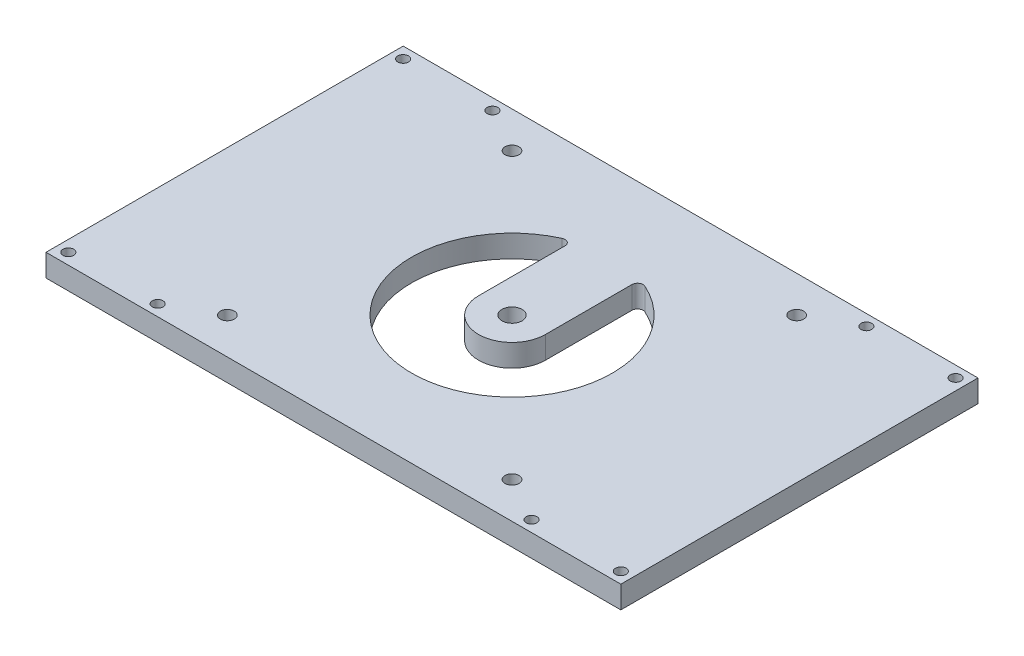
from build123d import *

# Parameters (mm, degrees)
SKETCH2_W          = 163.5125
SKETCH2_H          = 101.6
EXTRUDE1_DEPTH     = 6.35
SKETCH3_R          = 1.524
CUT_EXTRUDE1_DEPTH = 7.35
SKETCH4_R          = 1.984375
CUT_EXTRUDE2_DEPTH = 7.35
SKETCH5_R          = 2.850007
CUT_EXTRUDE3_DEPTH = 7.35
CUT_EXTRUDE4_DEPTH = 7.35


with BuildPart() as part:
    # Sketch2 → Extrude1 (new body)
    with BuildSketch(Plane(origin=(0, 0, 0), x_dir=(1, 0, 0), z_dir=(0, 1, 0))):
        with Locations((48.149449764, -29.875011174)):
            Rectangle(SKETCH2_W, SKETCH2_H)
    extrude(amount=EXTRUDE1_DEPTH)

    # Sketch3 → Cut-Extrude1 (cut, through all)
    with BuildSketch(Plane(origin=(0, 6.35, 0), x_dir=(1, 0, 0), z_dir=(0, 1, 0))):
        with Locations(Location((-30.431800236, 17.749988826, 0), (0, 0, 270))):  # turned: the seam where the file's is
            Circle(SKETCH3_R)
        with Locations(Location((-30.431800236, -77.500011174, 0), (0, 0, 270))):  # turned: the seam where the file's is
            Circle(SKETCH3_R)
        with Locations(Location((126.730699764, -77.500011174, 0), (0, 0, 270))):  # turned: the seam where the file's is
            Circle(SKETCH3_R)
        with Locations(Location((126.730699764, 17.749988826, 0), (0, 0, 270))):  # turned: the seam where the file's is
            Circle(SKETCH3_R)
        with Locations(Location((-5.031800236, 17.749988826, 0), (0, 0, 270))):  # turned: the seam where the file's is
            Circle(SKETCH3_R)
        with Locations(Location((-5.031800236, -77.500011174, 0), (0, 0, 270))):  # turned: the seam where the file's is
            Circle(SKETCH3_R)
        with Locations(Location((101.330699764, 17.749988826, 0), (0, 0, 270))):  # turned: the seam where the file's is
            Circle(SKETCH3_R)
        with Locations(Location((101.330699764, -77.500011174, 0), (0, 0, 270))):  # turned: the seam where the file's is
            Circle(SKETCH3_R)
    extrude(amount=-CUT_EXTRUDE1_DEPTH, mode=Mode.SUBTRACT)

    # Sketch4 → Cut-Extrude2 (cut, through all)
    with BuildSketch(Plane(origin=(0, 6.35, 0), x_dir=(1, 0, 0), z_dir=(0, 1, 0))):
        with Locations(Location((7.661849764, 10.612588826, 0), (0, 0, 270))):  # turned: the seam where the file's is
            Circle(SKETCH4_R)
        with Locations(Location((88.637049764, 10.612588826, 0), (0, 0, 270))):  # turned: the seam where the file's is
            Circle(SKETCH4_R)
        with Locations(Location((7.661849764, -70.362611174, 0), (0, 0, 270))):  # turned: the seam where the file's is
            Circle(SKETCH4_R)
        with Locations(Location((88.637049764, -70.362611174, 0), (0, 0, 270))):  # turned: the seam where the file's is
            Circle(SKETCH4_R)
    extrude(amount=-CUT_EXTRUDE2_DEPTH, mode=Mode.SUBTRACT)

    # Sketch5 → Cut-Extrude3 (cut, through all)
    with BuildSketch(Plane(origin=(0, 6.35, 0), x_dir=(1, 0, 0), z_dir=(0, 1, 0))):
        with Locations(Location((48.149449764, -29.875011174, 0), (0, 0, 270))):  # turned: the seam where the file's is
            Circle(SKETCH5_R)
    extrude(amount=-CUT_EXTRUDE3_DEPTH, mode=Mode.SUBTRACT)

    # Sketch6 → Cut-Extrude4 (cut, through all)
    with BuildSketch(Plane.XZ):
        with BuildLine():
            Line((38.624449764, 5.281566926), (38.624449764, 29.875011174))
            ThreePointArc((38.624449764, 29.875011174), (48.149449764, 39.400011174), (57.674449764, 29.875011174))
            Line((57.674449764, 29.875011174), (57.674449764, 5.281566926))
            ThreePointArc((57.674449764, 5.281566926), (58.40100701, 3.947800145), (59.915626235, 3.834893734))
            ThreePointArc((59.915626235, 3.834893734), (72.157251805, 14.378041594), (76.724449764, 29.875011174))
            ThreePointArc((76.724449764, 29.875011174), (32.652480184, 53.882813215), (36.383273294, 3.834893734))
            ThreePointArc((36.383273294, 3.834893734), (37.897892519, 3.947800145), (38.624449764, 5.281566926))
        make_face()
    extrude(amount=-CUT_EXTRUDE4_DEPTH, mode=Mode.SUBTRACT)


solid = part.part
